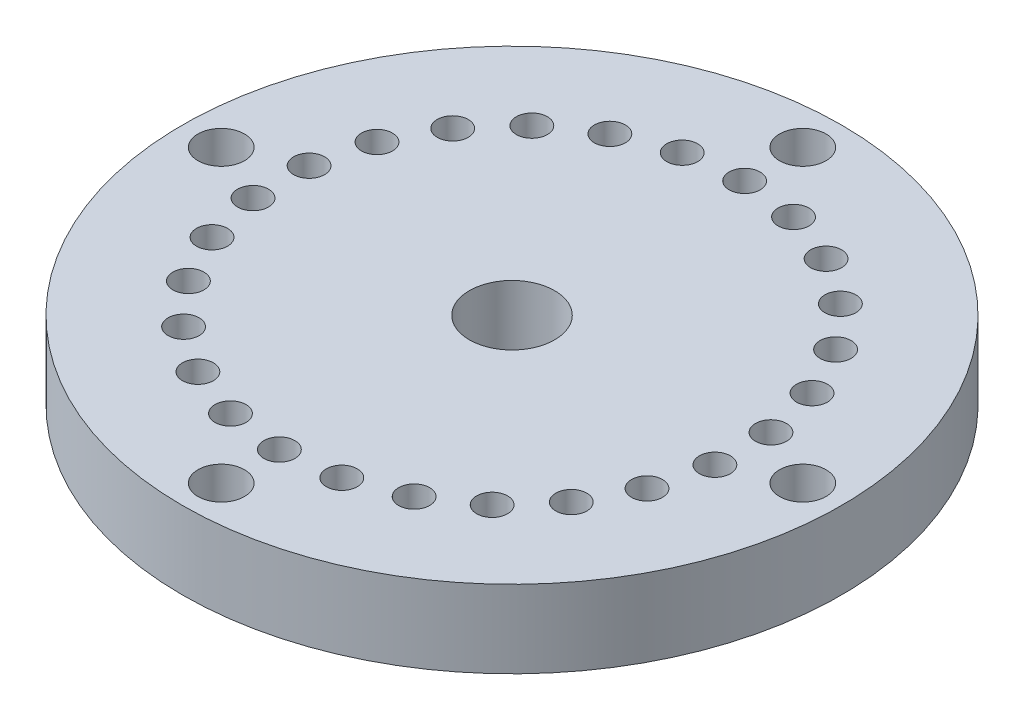
from build123d import *

# Parameters (mm, degrees)
ESQUISSE1_R        = 4.25
ESQUISSE1_R_2      = 0.55
ESQUISSE1_R_3      = 0.2
ESQUISSE1_R_4      = 0.3
BOSS_EXTRU_2_DEPTH = 1


with BuildPart() as part:
    # Esquisse1 → Boss.-Extru.2 (new body)
    with BuildSketch(Plane(origin=(0, 0, 0), x_dir=(1, 0, 0), z_dir=(0, 1, 0))):
        Circle(ESQUISSE1_R)
        Circle(ESQUISSE1_R_2, mode=Mode.SUBTRACT)
        with Locations((0, 3)):
            Circle(ESQUISSE1_R_3, mode=Mode.SUBTRACT)
        with Locations((0, 3.75)):
            Circle(ESQUISSE1_R_4, mode=Mode.SUBTRACT)
        with Locations((0.717946993, 2.912825452)):
            Circle(ESQUISSE1_R_3, mode=Mode.SUBTRACT)
        with Locations((1.394169516, 2.656368077)):
            Circle(ESQUISSE1_R_3, mode=Mode.SUBTRACT)
        with Locations((1.989367975, 2.245532245)):
            Circle(ESQUISSE1_R_3, mode=Mode.SUBTRACT)
        with Locations((2.468951598, 1.70419424)):
            Circle(ESQUISSE1_R_3, mode=Mode.SUBTRACT)
        with Locations((2.805048728, 1.063814661)):
            Circle(ESQUISSE1_R_3, mode=Mode.SUBTRACT)
        with Locations((2.978126622, 0.361610041)):
            Circle(ESQUISSE1_R_3, mode=Mode.SUBTRACT)
        with Locations((2.978126622, -0.361610041)):
            Circle(ESQUISSE1_R_3, mode=Mode.SUBTRACT)
        with Locations((2.805048728, -1.063814661)):
            Circle(ESQUISSE1_R_3, mode=Mode.SUBTRACT)
        with Locations((2.468951598, -1.70419424)):
            Circle(ESQUISSE1_R_3, mode=Mode.SUBTRACT)
        with Locations((1.989367975, -2.245532245)):
            Circle(ESQUISSE1_R_3, mode=Mode.SUBTRACT)
        with Locations((1.394169516, -2.656368077)):
            Circle(ESQUISSE1_R_3, mode=Mode.SUBTRACT)
        with Locations((0.717946993, -2.912825452)):
            Circle(ESQUISSE1_R_3, mode=Mode.SUBTRACT)
        with Locations((0, -3)):
            Circle(ESQUISSE1_R_3, mode=Mode.SUBTRACT)
        with Locations((-0.717946993, -2.912825452)):
            Circle(ESQUISSE1_R_3, mode=Mode.SUBTRACT)
        with Locations((-1.394169516, -2.656368077)):
            Circle(ESQUISSE1_R_3, mode=Mode.SUBTRACT)
        with Locations((-1.989367975, -2.245532245)):
            Circle(ESQUISSE1_R_3, mode=Mode.SUBTRACT)
        with Locations((-2.468951598, -1.70419424)):
            Circle(ESQUISSE1_R_3, mode=Mode.SUBTRACT)
        with Locations((-2.805048728, -1.063814661)):
            Circle(ESQUISSE1_R_3, mode=Mode.SUBTRACT)
        with Locations((-2.978126622, -0.361610041)):
            Circle(ESQUISSE1_R_3, mode=Mode.SUBTRACT)
        with Locations((-2.978126622, 0.361610041)):
            Circle(ESQUISSE1_R_3, mode=Mode.SUBTRACT)
        with Locations((-2.805048728, 1.063814661)):
            Circle(ESQUISSE1_R_3, mode=Mode.SUBTRACT)
        with Locations((-2.468951598, 1.70419424)):
            Circle(ESQUISSE1_R_3, mode=Mode.SUBTRACT)
        with Locations((-1.989367975, 2.245532245)):
            Circle(ESQUISSE1_R_3, mode=Mode.SUBTRACT)
        with Locations((-1.394169516, 2.656368077)):
            Circle(ESQUISSE1_R_3, mode=Mode.SUBTRACT)
        with Locations((-0.717946993, 2.912825452)):
            Circle(ESQUISSE1_R_3, mode=Mode.SUBTRACT)
        with Locations((3.75, 0)):
            Circle(ESQUISSE1_R_4, mode=Mode.SUBTRACT)
        with Locations((0, -3.75)):
            Circle(ESQUISSE1_R_4, mode=Mode.SUBTRACT)
        with Locations((-3.75, 0)):
            Circle(ESQUISSE1_R_4, mode=Mode.SUBTRACT)
    extrude(amount=BOSS_EXTRU_2_DEPTH)


solid = part.part
